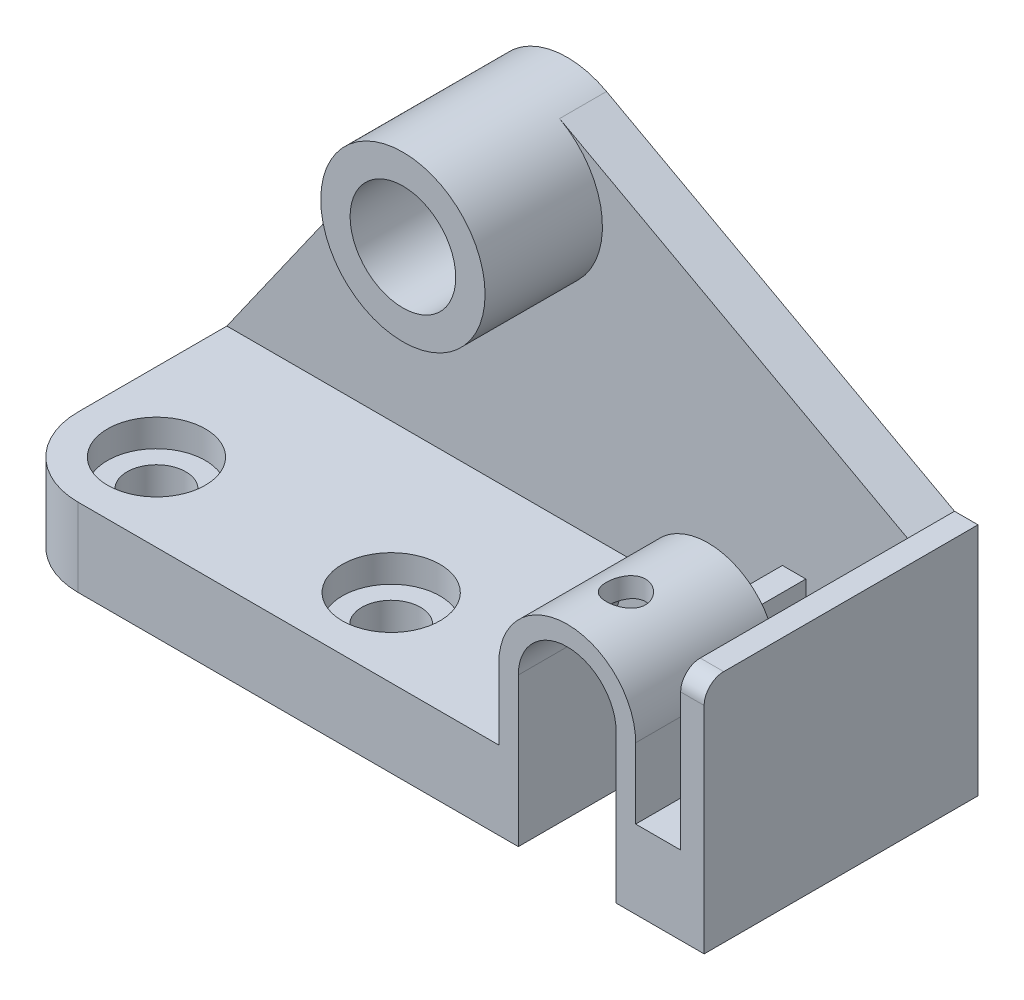
from build123d import *

# Parameters (mm, degrees)
SKETCH1_R               = 21
BOSS_EXTRUDE1_DEPTH     = 42
BOSS_EXTRUDE2_DEPTH     = 12
BOSS_EXTRUDE5_DEPTH     = 70
SKETCH2_W               = 35
SKETCH2_H               = 22
CUT_EXTRUDE2_DEPTH      = 70
CUT_EXTRUDE4_DEPTH      = 1
CUT_EXTRUDE4_DEPTH_BACK = 25
SKETCH5_W               = 6
SKETCH5_H               = 18
BOSS_EXTRUDE6_DEPTH     = 33
FILLET1_R               = 5
SKETCH8_W               = 25
SKETCH8_H               = 6
CUT_EXTRUDE6_DEPTH      = 167
SKETCH7_R               = 7.5
CUT_EXTRUDE7_DEPTH      = 167
SKETCH7_3_R             = 12.5
CUT_EXTRUDE8_DEPTH      = 7
FILLET2_R               = 20
SKETCH7_4_R             = 12.5
SKETCH7_4_R_2           = 7.5
CUT_EXTRUDE9_DEPTH      = 7
SKETCH7_5_R             = 7.5
CUT_EXTRUDE10_DEPTH     = 21
SKETCH11_R              = 5
CUT_EXTRUDE11_DEPTH     = 80


with BuildPart() as part:
    # Sketch1 → Boss-Extrude1 (new body)
    with BuildSketch(Plane.XY):
        Circle(SKETCH1_R)
    extrude(amount=BOSS_EXTRUDE1_DEPTH)

    # Sketch1_3 → Boss-Extrude2 (add)
    with BuildSketch(Plane.XY):
        with BuildLine():
            ThreePointArc((21, 0), (-6.343349758, -20.019038784), (-17.167801318, 12.094072841))
            Line((-17.167801318, 12.094072841), (-75, -70))
            Line((-75, -70), (52.5, -70))
            Line((52.5, -70), (52.5, -52))
            ThreePointArc((52.5, -52), (70, -34.5), (87.5, -52))
            Line((87.5, -52), (87.5, -70))
            Line((87.5, -70), (99, -70))
            Line((99, -70), (99, -30))
            Line((99, -30), (10.043243118, 18.442702288))
            ThreePointArc((10.043243118, 18.442702288), (18.054197649, 10.725947383), (21, 0))
        make_face()
    extrude(amount=BOSS_EXTRUDE2_DEPTH)

    # Sketch1_7 → Boss-Extrude5 (add)
    with BuildSketch(Plane.XY):
        with BuildLine():
            Line((52.5, -70), (-75, -70))
            Line((-75, -70), (-75, -90))
            Line((-75, -90), (105, -90))
            Line((105, -90), (105, -30))
            Line((105, -30), (99, -30))
            Line((99, -30), (99, -70))
            Line((99, -70), (87.5, -70))
            Line((87.5, -70), (87.5, -52))
            ThreePointArc((87.5, -52), (70, -34.5), (52.5, -52))
            Line((52.5, -52), (52.5, -70))
        make_face()
    extrude(amount=BOSS_EXTRUDE5_DEPTH)

    # Sketch2 → Cut-Extrude2 (cut)
    with BuildSketch(Plane(origin=(0, 0, 0), x_dir=(1, 0, 0), z_dir=(0, 1, 0))):
        with Locations((70, -23)):
            Rectangle(SKETCH2_W, SKETCH2_H)
    extrude(amount=-CUT_EXTRUDE2_DEPTH, mode=Mode.SUBTRACT)

    # Sketch3 → Cut-Extrude4 (cut, two sides)
    with BuildSketch(Plane.XY.offset(70)) as cut_extrude4_sk:
        with BuildLine():
            Line((57.5, -52), (57.5, -90))
            Line((57.5, -90), (82.5, -90))
            Line((82.5, -90), (82.5, -52))
            ThreePointArc((82.5, -52), (70, -39.5), (57.5, -52))
        make_face()
    extrude(amount=CUT_EXTRUDE4_DEPTH, mode=Mode.SUBTRACT)
    extrude(cut_extrude4_sk.sketch, amount=-CUT_EXTRUDE4_DEPTH_BACK, mode=Mode.SUBTRACT)

    # Sketch5 → Boss-Extrude6 (add)
    with BuildSketch(Plane.XY.offset(45)):
        with Locations((70, -61)):
            Rectangle(SKETCH5_W, SKETCH5_H)
    extrude(amount=-BOSS_EXTRUDE6_DEPTH)

    # Fillet1
    fillet1_edges = [part.edges().sort_by_distance(p)[0] for p in [
        (102, -30, 70),
    ]]
    fillet(fillet1_edges, radius=FILLET1_R)

    # Sketch8 → Cut-Extrude6 (cut)
    with BuildSketch(Plane.XY.offset(45)):
        with Locations((70, -87)):
            Rectangle(SKETCH8_W, SKETCH8_H)
    extrude(amount=-CUT_EXTRUDE6_DEPTH, mode=Mode.SUBTRACT)

    # Sketch7 → Cut-Extrude7 (cut)
    with BuildSketch(Plane(origin=(0, -70, 0), x_dir=(1, 0, 0), z_dir=(0, 1, 0))):
        with Locations((-55, -50)):
            Circle(SKETCH7_R)
    extrude(amount=-CUT_EXTRUDE7_DEPTH, mode=Mode.SUBTRACT)

    # Sketch7_3 → Cut-Extrude8 (cut)
    with BuildSketch(Plane(origin=(0, -70, 0), x_dir=(1, 0, 0), z_dir=(0, 1, 0))):
        with Locations((-55, -50)):
            Circle(SKETCH7_3_R)
    extrude(amount=-CUT_EXTRUDE8_DEPTH, mode=Mode.SUBTRACT)

    # Fillet2
    fillet2_edges = [part.edges().sort_by_distance(p)[0] for p in [
        (-75, -80, 70),
    ]]
    fillet(fillet2_edges, radius=FILLET2_R)

    # Sketch7_4 → Cut-Extrude9 (cut)
    with BuildSketch(Plane(origin=(0, -70, 0), x_dir=(1, 0, 0), z_dir=(0, 1, 0))):
        with Locations((5, -50)):
            Circle(SKETCH7_4_R)
        with Locations((5, -50)):
            Circle(SKETCH7_4_R_2, mode=Mode.SUBTRACT)
    extrude(amount=-CUT_EXTRUDE9_DEPTH, mode=Mode.SUBTRACT)

    # Sketch7_5 → Cut-Extrude10 (cut, through all)
    with BuildSketch(Plane(origin=(0, -70, 0), x_dir=(1, 0, 0), z_dir=(0, 1, 0))):
        with Locations((5, -50)):
            Circle(SKETCH7_5_R)
    extrude(amount=-CUT_EXTRUDE10_DEPTH, mode=Mode.SUBTRACT)

    # Sketch10 → Cut-Revolve1 (revolve, cut)
    with BuildSketch(Plane(origin=(0, 0, 0), x_dir=(1, 0, 0), z_dir=(0, 1, 0))):
        Polygon((0, 0), (0, -42.225297228), (13.5, -42.225297228), (13.5, -20.830460942), (7.5, -17.225297228), (7.5, 0), align=None)
    revolve(axis=Axis((0, 0, 0), (0, 0, 1)), mode=Mode.SUBTRACT)

    # Sketch11 → Cut-Extrude11 (cut)
    with BuildSketch(Plane(origin=(0, 0, 0), x_dir=(1, 0, 0), z_dir=(0, 1, 0))):
        with Locations((70, -55)):
            Circle(SKETCH11_R)
    extrude(amount=-CUT_EXTRUDE11_DEPTH, mode=Mode.SUBTRACT)


solid = part.part
